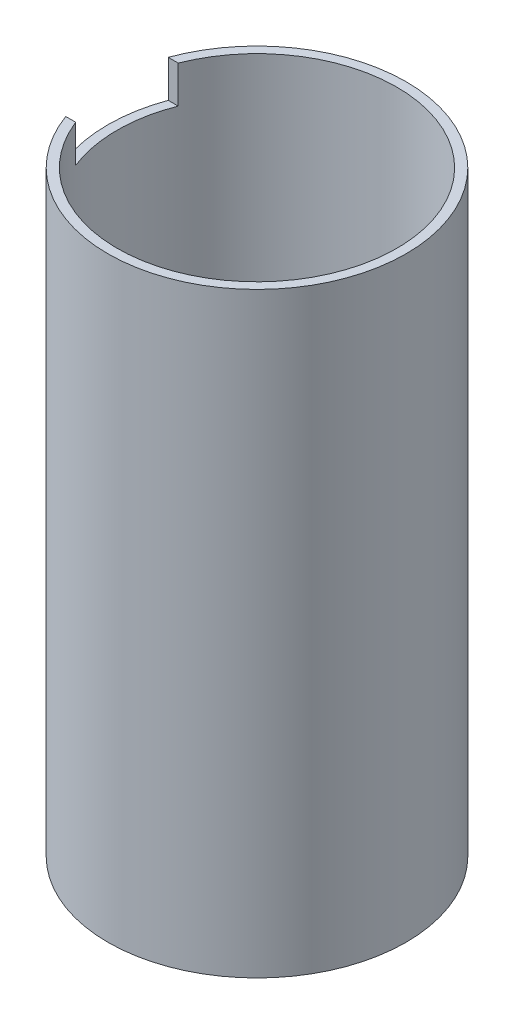
from build123d import *

# Parameters (mm, degrees)
SKETCH1_R           = 16
SKETCH1_R_2         = 15
BOSS_EXTRUDE1_DEPTH = 64
CUT_EXTRUDE1_DEPTH  = 4
CUT_EXTRUDE2_DEPTH  = 4


with BuildPart() as part:
    # Sketch1 → Boss-Extrude1 (new body)
    with BuildSketch(Plane(origin=(0, 0, 0), x_dir=(1, 0, 0), z_dir=(0, 1, 0))):
        Circle(SKETCH1_R)
        Circle(SKETCH1_R_2, mode=Mode.SUBTRACT)
    extrude(amount=BOSS_EXTRUDE1_DEPTH)

    # Sketch2 → Cut-Extrude1 (cut)
    with BuildSketch(Plane(origin=(0, 64, 0), x_dir=(1, 0, 0), z_dir=(0, 1, 0))):
        Polygon((0, 0), (0, 5.5), (-16.81016258, 5.5), (-16.81016258, -5.5), (0, -5.5), align=None)
    extrude(amount=-CUT_EXTRUDE1_DEPTH, mode=Mode.SUBTRACT)

    # Sketch3 → Cut-Extrude2 (cut)
    with BuildSketch(Plane.XZ):
        Polygon((0, 0), (0, 5.5), (-17.011405804, 5.5), (-17.011405804, -5.5), (0, -5.5), align=None)
    extrude(amount=-CUT_EXTRUDE2_DEPTH, mode=Mode.SUBTRACT)


solid = part.part
